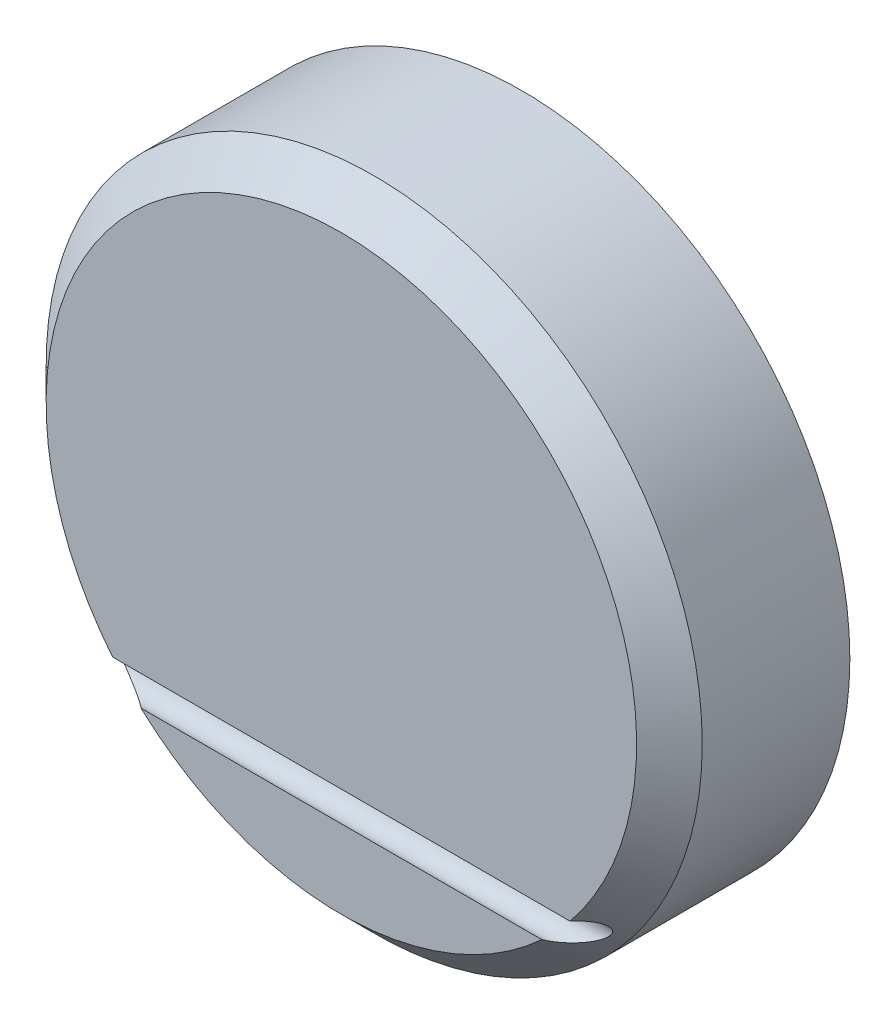
from build123d import *

# Parameters (mm, degrees)
SKETCH1_R               = 10
SKETCH1_R_2             = 8.25
BOSS_EXTRUDE1_DEPTH     = 4.5
SKETCH1_3_R             = 8.25
BOSS_EXTRUDE2_DEPTH     = 1
SKETCH2_R               = 10
SKETCH2_R_2             = 9.2
BOSS_EXTRUDE3_DEPTH     = 1
CHAMFER1_SIZE           = 1
CHAMFER2_SIZE           = 0.5
CUT_EXTRUDE3_DEPTH      = 16.173990905
CUT_EXTRUDE3_DEPTH_BACK = 16.173990905
SKETCH4_R               = 0.5


with BuildPart() as part:
    # Sketch1 → Boss-Extrude1 (new body)
    with BuildSketch(Plane.XY):
        Circle(SKETCH1_R)
        Circle(SKETCH1_R_2, mode=Mode.SUBTRACT)
    extrude(amount=-BOSS_EXTRUDE1_DEPTH)

    # Sketch1_3 → Boss-Extrude2 (add)
    with BuildSketch(Plane.XY):
        Circle(SKETCH1_3_R)
    extrude(amount=-BOSS_EXTRUDE2_DEPTH)

    # Sketch2 → Boss-Extrude3 (add)
    with BuildSketch(Plane(origin=(0, 0, -4.5), x_dir=(-1, 0, 0), z_dir=(0, 0, -1))):
        Circle(SKETCH2_R)
        Circle(SKETCH2_R_2, mode=Mode.SUBTRACT)
    extrude(amount=BOSS_EXTRUDE3_DEPTH)

    # Chamfer1
    chamfer1_edges = [part.edges().sort_by_distance(p)[0] for p in [
        (-10, 0, 0),
    ]]
    chamfer(chamfer1_edges, length=CHAMFER1_SIZE)

    # Chamfer2
    chamfer2_edges = [part.edges().sort_by_distance(p)[0] for p in [
        (-8.25, 0, -1),
    ]]
    chamfer(chamfer2_edges, length=CHAMFER2_SIZE)

    # Sketch4 → Cut-Extrude3 (cut, two sides: drawn at the far end of the back side and taken through both)
    with BuildSketch(Plane(origin=(0, 0, 0), x_dir=(0, 0, -1), z_dir=(1, 0, 0)).offset(-CUT_EXTRUDE3_DEPTH_BACK)):
        with Locations((0.2, -6.15)):
            Circle(SKETCH4_R)
    extrude(amount=CUT_EXTRUDE3_DEPTH + CUT_EXTRUDE3_DEPTH_BACK, mode=Mode.SUBTRACT)


solid = part.part
